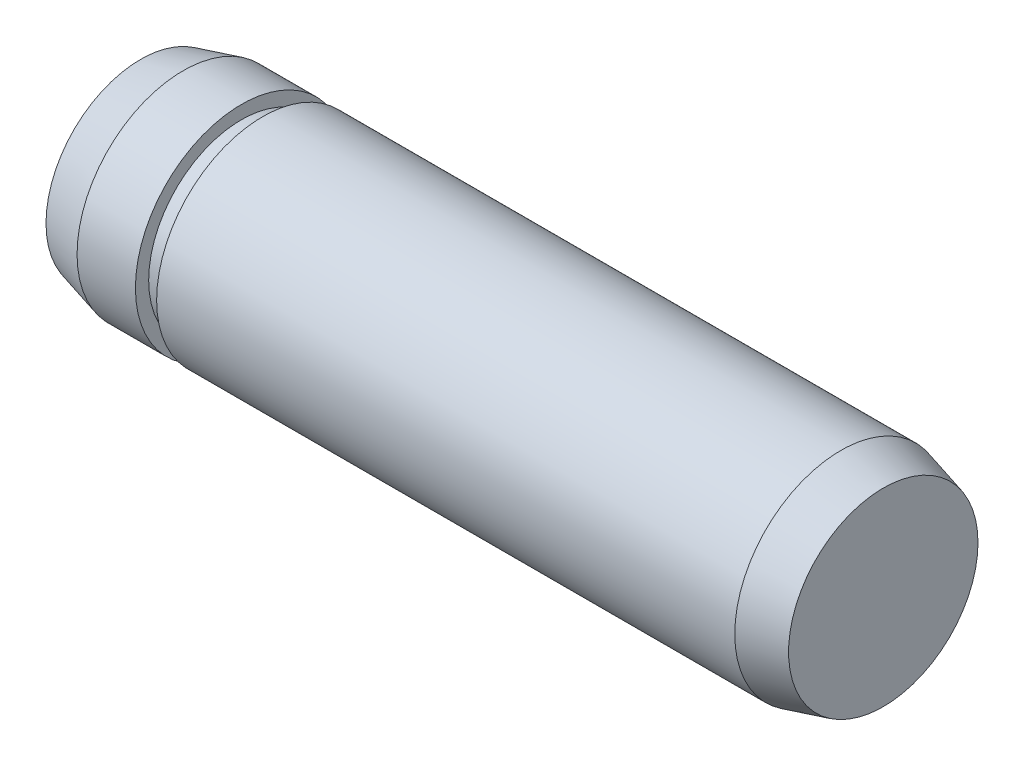
from build123d import *

# Parameters (mm, degrees)
SKETCH2_R           = 4
EXTRUDE1_DEPTH      = 12.4
EXTRUDE1_DEPTH_BACK = 12.4
SKETCH3_R           = 4
EXTRUDE2_DEPTH      = 1.6
EXTRUDE2_TAPER      = 15
SKETCH4_R           = 4
EXTRUDE3_DEPTH      = 1.6
EXTRUDE3_TAPER      = 15
SKETCH5_R           = 4
SKETCH5_R_2         = 3.5
CUT_EXTRUDE1_DEPTH  = 0.8


with BuildPart() as part:
    # Sketch2 → Extrude1 (new body, two sides)
    with BuildSketch(Plane(origin=(0, 0, 0), x_dir=(0, 0, -1), z_dir=(1, 0, 0))) as extrude1_sk:
        Circle(SKETCH2_R)
    extrude(amount=EXTRUDE1_DEPTH)
    extrude(extrude1_sk.sketch, amount=-EXTRUDE1_DEPTH_BACK)

    # Sketch3 → Extrude2 (add)
    with BuildSketch(Plane(origin=(12.4, 0, 0), x_dir=(0, 0, -1), z_dir=(1, 0, 0))):
        Circle(SKETCH3_R)
    extrude(amount=EXTRUDE2_DEPTH, taper=EXTRUDE2_TAPER)

    # Sketch4 → Extrude3 (add)
    with BuildSketch(Plane.ZY.offset(12.4)):
        Circle(SKETCH4_R)
    extrude(amount=EXTRUDE3_DEPTH, taper=EXTRUDE3_TAPER)

    # Sketch5 → Cut-Extrude1 (cut)
    with BuildSketch(Plane.ZY.offset(9.40000006)):
        Circle(SKETCH5_R)
        Circle(SKETCH5_R_2, mode=Mode.SUBTRACT)
    extrude(amount=CUT_EXTRUDE1_DEPTH, mode=Mode.SUBTRACT)


solid = part.part
